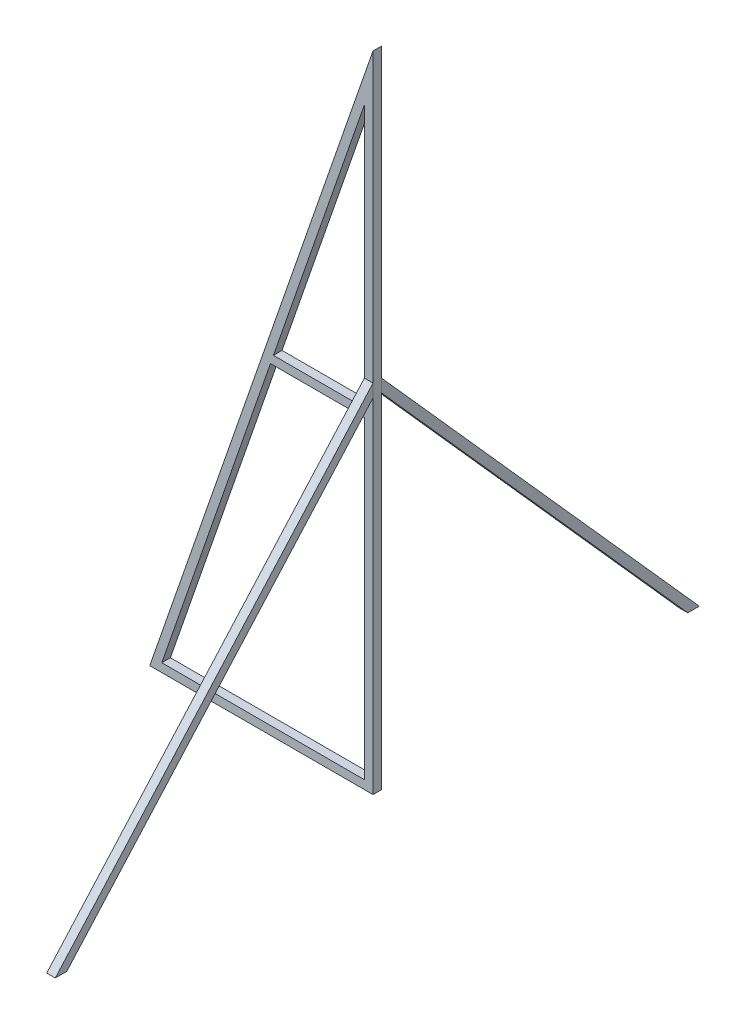
from build123d import *

# Parameters (mm, degrees)
EXTRUDE_1_DEPTH   = 2
EXTRUDE_2_DEPTH   = 2
EXTRUDE_2_2_DEPTH = 2


with BuildPart() as part:
    # ｽｹｯﾁ1 → ﾎﾞｽ - 押し出し1 (new body)
    with BuildSketch(Plane.XY):
        Polygon((52, 0), (52, 150), (0, 0), align=None)
        Polygon((50, 2), (50, 138.124704732), (2.81010236, 2), align=None, mode=Mode.SUBTRACT)
        Polygon((50, 77), (28.81010236, 77), (28.116769026, 75), (50, 75), align=None)
    extrude(amount=EXTRUDE_1_DEPTH)


with BuildPart() as body_2:
    # ｽｹｯﾁ2 → ﾎﾞｽ - 押し出し2 (new body)
    with BuildSketch(Plane(origin=(52, 0, 0), x_dir=(0, 0, -1), z_dir=(1, 0, 0))):
        Polygon((-2, 83.005462125), (-76, 0), (-73.320607685, 0), (-2, 80), align=None)
    extrude(amount=-EXTRUDE_2_DEPTH)


with BuildPart() as body_3:
    # ｽｹｯﾁ2 → Extrude 2 2 (new body)
    with BuildSketch(Plane(origin=(52, 0, 0), x_dir=(0, 0, -1), z_dir=(1, 0, 0))):
        Polygon((74, 0), (71.320607685, 0), (0, 80), (0, 83.005462125), align=None)
    extrude(amount=-EXTRUDE_2_2_DEPTH)


solid = Compound([part.part, body_2.part, body_3.part])
